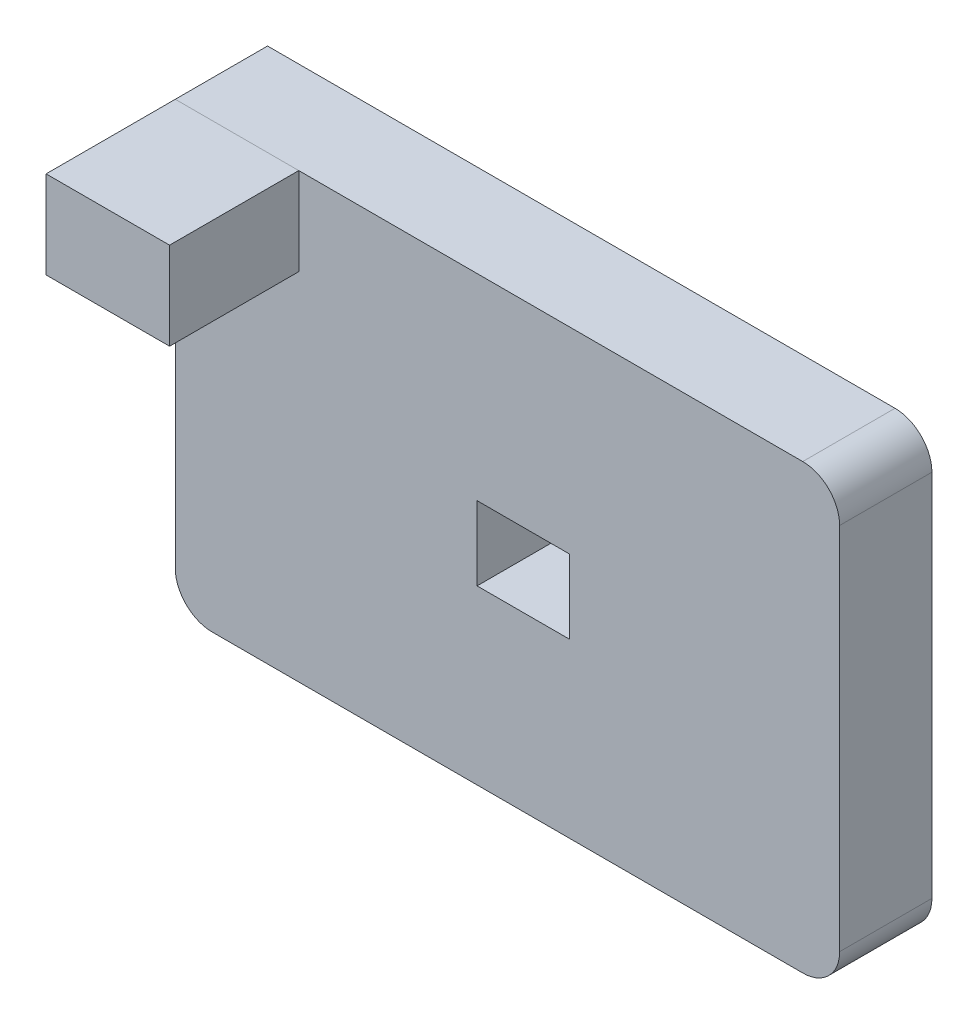
from build123d import *

# Parameters (mm, degrees)
SKETCH1_W           = 180
SKETCH1_H           = 120
SKETCH1_W_2         = 25
SKETCH1_H_2         = 20
BOSS_EXTRUDE1_DEPTH = 25
SKETCH2_W           = 33.457845935
SKETCH2_H           = 23.718784475
BOSS_EXTRUDE2_DEPTH = 35
FILLET1_R           = 10


with BuildPart() as part:
    # Sketch1 → Boss-Extrude1 (new body)
    with BuildSketch(Plane.XY):
        with Locations((90, 60)):
            Rectangle(SKETCH1_W, SKETCH1_H)
        with Locations((94.273136822, 56.710774072)):
            Rectangle(SKETCH1_W_2, SKETCH1_H_2, mode=Mode.SUBTRACT)
    extrude(amount=BOSS_EXTRUDE1_DEPTH)

    # Fillet1
    fillet1_edges = [part.edges().sort_by_distance(p)[0] for p in [
        (0, 0, 12.5),
        (180, 0, 12.5),
        (180, 120, 12.5),
    ]]
    fillet(fillet1_edges, radius=FILLET1_R)


with BuildPart() as body_2:
    # Sketch2 → Boss-Extrude2 (new body)
    with BuildSketch(Plane.XY.offset(25)):
        with Locations((16.728922968, 108.140607763)):
            Rectangle(SKETCH2_W, SKETCH2_H)
    extrude(amount=BOSS_EXTRUDE2_DEPTH)


solid = Compound([part.part, body_2.part])
